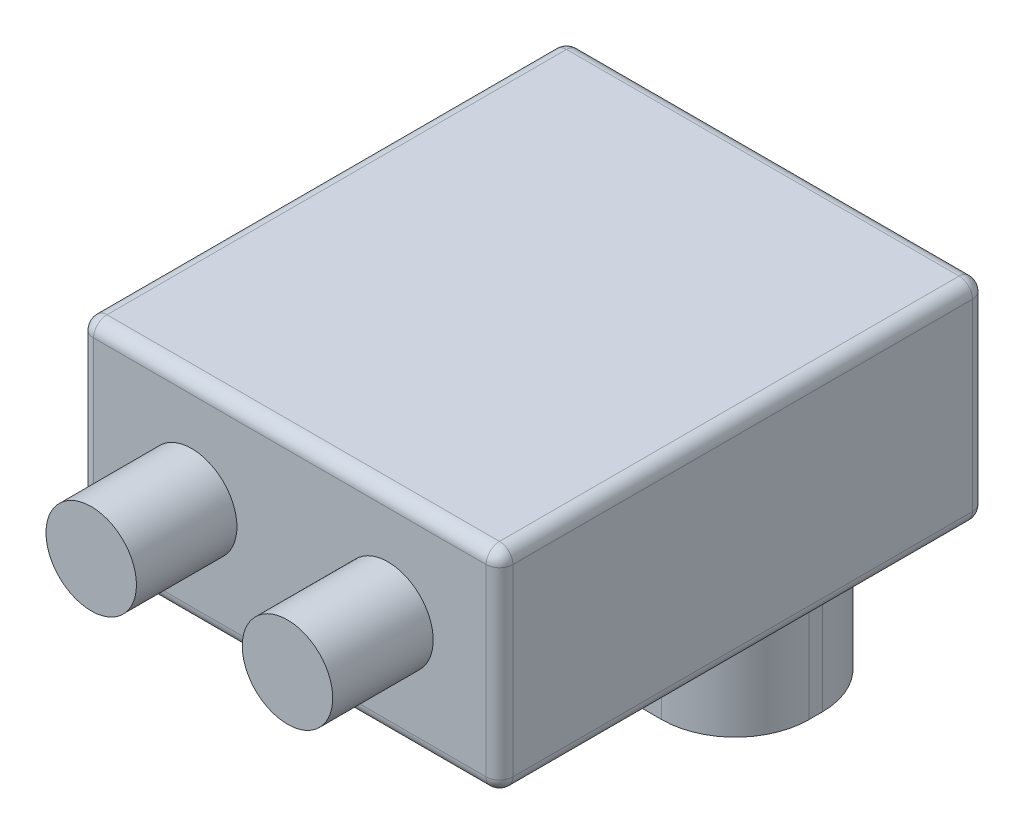
from build123d import *

# Parameters (mm, degrees)
SKETCH1_W           = 62.6
SKETCH1_H           = 72.6
BOSS_EXTRUDE1_DEPTH = 24.14
SKETCH2_W           = 50
SKETCH2_H           = 24
BOSS_EXTRUDE2_DEPTH = 19
SKETCH3_W           = 62.6
SKETCH3_H           = 72.6
BOSS_EXTRUDE3_DEPTH = 7.3
FILLET1_R           = 2
FILLET2_R           = 11
SKETCH4_R           = 6.75
BOSS_EXTRUDE4_DEPTH = 15


with BuildPart() as part:
    # Sketch1 → Boss-Extrude1 (new body)
    with BuildSketch(Plane(origin=(0, 0, 0), x_dir=(1, 0, 0), z_dir=(0, 1, 0))):
        Rectangle(SKETCH1_W, SKETCH1_H)
    extrude(amount=BOSS_EXTRUDE1_DEPTH)

    # Sketch2 → Boss-Extrude2 (add)
    with BuildSketch(Plane.XZ):
        with Locations((0, -17.2)):
            Rectangle(SKETCH2_W, SKETCH2_H)
    extrude(amount=BOSS_EXTRUDE2_DEPTH)

    # Sketch3 → Boss-Extrude3 (add)
    with BuildSketch(Plane(origin=(0, 24.14, 0), x_dir=(1, 0, 0), z_dir=(0, 1, 0))):
        Rectangle(SKETCH3_W, SKETCH3_H)
    extrude(amount=BOSS_EXTRUDE3_DEPTH)

    # Fillet1
    fillet1_edges = [part.edges().sort_by_distance(p)[0] for p in [
        (0, 31.44, 36.3),
        (31.3, 31.44, 0),
        (0, 31.44, -36.3),
        (-31.3, 31.44, 0),
        (0, 0, 36.3),
        (-31.3, 0, 0),
        (0, 0, -36.3),
        (31.3, 0, 0),
        (31.3, 15.72, 36.3),
        (-31.3, 15.72, 36.3),
        (-31.3, 15.72, -36.3),
        (31.3, 15.72, -36.3),
    ]]
    fillet(fillet1_edges, radius=FILLET1_R)

    # Fillet2
    fillet2_edges = [part.edges().sort_by_distance(p)[0] for p in [
        (-25, -9.5, -5.2),
        (-25, -9.5, -29.2),
        (25, -9.5, -29.2),
        (25, -9.5, -5.2),
    ]]
    fillet(fillet2_edges, radius=FILLET2_R)

    # Sketch4 → Boss-Extrude4 (add)
    with BuildSketch(Plane.XY.offset(36.3)):
        with Locations((-14.64999991, 15.7200005)):
            Circle(SKETCH4_R)
        with Locations((14.64999991, 15.7200005)):
            Circle(SKETCH4_R)
    extrude(amount=BOSS_EXTRUDE4_DEPTH)


solid = part.part
